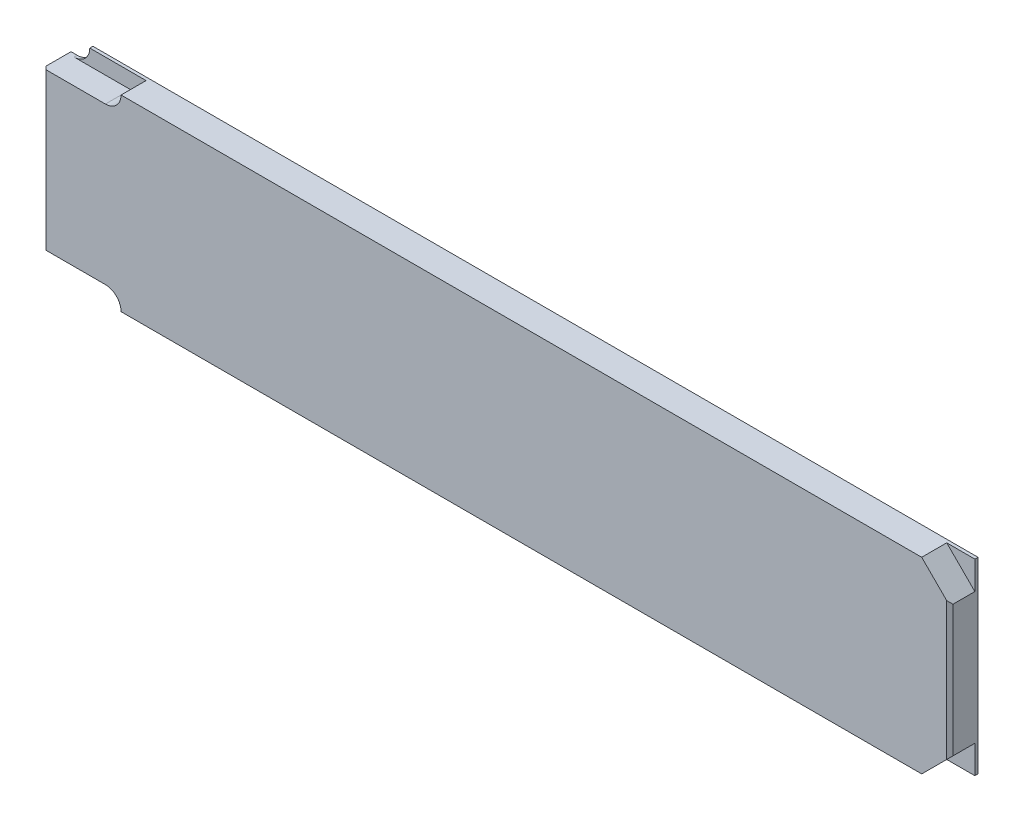
from build123d import *

# Parameters (mm, degrees)
BASE_EXTRUDE_DEPTH = 9
CUT_EXTRUDE1_DEPTH = 8
CHAMFER1_SIZE      = 1
CUT_EXTRUDE2_DEPTH = 0.13


with BuildPart() as part:
    # Sketch1 → Base-Extrude (new body)
    with BuildSketch(Plane.XY):
        with BuildLine():
            Line((7, 0), (290, 0))
            Line((290, 0), (290, 60))
            Line((290, 60), (7, 60))
            ThreePointArc((7, 60), (5.535533906, 56.464466094), (2, 55))
            Line((2, 55), (0, 55))
            Line((0, 55), (0, 5))
            Line((0, 5), (2, 5))
            ThreePointArc((2, 5), (5.535533906, 3.535533906), (7, 0))
        make_face()
    extrude(amount=BASE_EXTRUDE_DEPTH)

    # Sketch2 → Cut-Extrude1 (cut)
    with BuildSketch(Plane.XY.offset(9)):
        with BuildLine():
            Line((2, 5), (20, 5))
            ThreePointArc((20, 5), (23.535533906, 3.535533906), (25, 0))
            Line((25, 0), (7, 0))
            ThreePointArc((7, 0), (5.535533906, 3.535533906), (2, 5))
        make_face()
        Polygon((290, 60), (290, 51), (281, 60), align=None)
        Polygon((290, 9), (281, 0), (290, 0), align=None)
        with BuildLine():
            Line((25, 60), (7, 60))
            ThreePointArc((7, 60), (5.535533906, 56.464466094), (2, 55))
            Line((2, 55), (20, 55))
            ThreePointArc((20, 55), (23.535533906, 56.464466094), (25, 60))
        make_face()
    extrude(amount=-CUT_EXTRUDE1_DEPTH, mode=Mode.SUBTRACT)

    # Chamfer1
    chamfer1_edges = [part.edges().sort_by_distance(p)[0] for p in [
        (0, 30, 9),
        (290, 30, 9),
    ]]
    chamfer(chamfer1_edges, length=CHAMFER1_SIZE)

    # Sketch3 → Cut-Extrude2 (cut)
    with BuildSketch(Plane(origin=(0, 0, 0), x_dir=(-1, 0, 0), z_dir=(0, 0, -1))):
        with BuildLine():
            Line((-111.030175307, 29.245794241), (-110.20501925, 28.597628179))
            Line((-110.20501925, 28.597628179), (-113.359746321, 23.77345494))
            add(Edge.make_bspline(
                [(-113.359746321, 23.77345494), (-113.149709887, 23.806933241), (-112.740010074, 23.872236454), (-112.325308872, 23.883009243), (-112.123208114, 23.888259261)],
                knots=[0, 0, 0, 0, 1.025318673, 2, 2, 2, 2], degree=3))
            add(Edge.make_bspline(
                [(-112.123208114, 23.888259261), (-112.001858647, 23.88499765), (-111.762985832, 23.878577266), (-111.412278069, 23.829168095), (-111.075276566, 23.751304142), (-110.753378119, 23.637801551), (-110.445427333, 23.492812062), (-110.149656987, 23.319042848), (-109.871626865, 23.10752111), (-109.607756591, 22.871235599), (-109.3681889, 22.609528771), (-109.156085956, 22.33184208), (-108.977923218, 22.038464833), (-108.833371856, 21.729545624), (-108.72112251, 21.405560647), (-108.639292775, 21.066924424), (-108.590921527, 20.713403443), (-108.584353046, 20.472979242), (-108.581016459, 20.35085112)],
                knots=[0, 0, 0, 0, 1.04369286, 2.054478336, 3.041073146, 4.015093852, 4.984733326, 5.965804835, 6.960378782, 7.985147595, 9.009457201, 10.008161701, 10.986880575, 11.956520048, 12.937015923, 13.931873656, 14.949455224, 16, 16, 16, 16], degree=3))
            add(Edge.make_bspline(
                [(-108.581016459, 20.35085112), (-108.585871137, 20.183765265), (-108.595423995, 19.854979844), (-108.690613006, 19.3761088), (-108.838526994, 18.919903272), (-109.049952696, 18.49364697), (-109.312564885, 18.097924111), (-109.632812183, 17.747289134), (-109.999337206, 17.434572533), (-110.41376857, 17.173071631), (-110.859775756, 16.959512065), (-111.328328525, 16.806120858), (-111.814876559, 16.711683453), (-112.145108868, 16.699844087), (-112.312156892, 16.693855144)],
                knots=[0, 0, 0, 0, 1.031375318, 2.029502543, 3.004789286, 3.987476834, 4.960371455, 5.9300674, 6.912260825, 7.929083631, 8.949397511, 9.960523116, 10.96833055, 12, 12, 12, 12], degree=3))
            add(Edge.make_bspline(
                [(-112.312156892, 16.693855144), (-112.472819204, 16.699068356), (-112.791063115, 16.709394815), (-113.259209243, 16.801384485), (-113.709037298, 16.950483765), (-114.137395693, 17.155894444), (-114.534203503, 17.41535286), (-114.889205564, 17.727701862), (-115.200631786, 18.086264765), (-115.459806168, 18.490985951), (-115.665368492, 18.925896063), (-115.819526166, 19.379388359), (-115.90957242, 19.849810483), (-115.922155299, 20.168705347), (-115.928493004, 20.329325309)],
                knots=[0, 0, 0, 0, 1.012016664, 2.004627821, 2.994792927, 3.992885782, 4.990978636, 5.973936114, 6.964471063, 7.975201453, 8.993600317, 9.990122807, 10.98767138, 12, 12, 12, 12], degree=3))
            add(Edge.make_bspline(
                [(-115.928493004, 20.329325309), (-115.924462707, 20.45228522), (-115.916233611, 20.703345863), (-115.858775275, 21.083586266), (-115.766448372, 21.47265196), (-115.663050168, 21.802712288), (-115.553800295, 22.073099369), (-115.46287973, 22.291095161), (-115.349712335, 22.515427777), (-115.229042116, 22.753789696), (-115.090007051, 23.000037912), (-114.938831818, 23.258287989), (-114.771336785, 23.524432761), (-114.653918306, 23.705042798), (-114.593892772, 23.797372507)],
                knots=[0, 0, 0, 0, 1.173818275, 2.396712641, 3.66331629, 4.989737886, 5.693666774, 6.447286557, 7.243889047, 8.091586357, 8.998013824, 9.943181721, 10.948533338, 12, 12, 12, 12], degree=3))
            Line((-114.593892772, 23.797372507), (-111.030175307, 29.245794241))
        make_face()
        with BuildLine():
            add(Edge.make_bspline(
                [(-112.348033242, 22.663679837), (-112.438986915, 22.661025674), (-112.61664586, 22.655841324), (-112.877296643, 22.625735491), (-113.123980891, 22.569042401), (-113.359966812, 22.496837092), (-113.580842489, 22.397556998), (-113.788213185, 22.276960402), (-113.982880817, 22.134976895), (-114.162806392, 21.973617954), (-114.325934968, 21.796951966), (-114.466417329, 21.60772721), (-114.587595901, 21.410503978), (-114.68612127, 21.203634398), (-114.762842304, 20.987197553), (-114.81833865, 20.762188892), (-114.849223969, 20.527099563), (-114.854362219, 20.367679649), (-114.856986008, 20.286273689)],
                knots=[0, 0, 0, 0, 1.129588631, 2.206414736, 3.251139165, 4.268635594, 5.265702196, 6.250456724, 7.242448911, 8.251968645, 9.246821453, 10.222880186, 11.173611482, 12.116736599, 13.062300278, 14.020270554, 14.989073742, 16, 16, 16, 16], degree=3))
            add(Edge.make_bspline(
                [(-114.856986008, 20.286273689), (-114.854849283, 20.205595841), (-114.850659484, 20.047398592), (-114.812615259, 19.814271208), (-114.754502998, 19.589925509), (-114.668058587, 19.375518065), (-114.564944745, 19.167780726), (-114.428814579, 18.974238036), (-114.277976602, 18.78313518), (-114.097674478, 18.609152412), (-113.904172459, 18.447262282), (-113.697441856, 18.305759516), (-113.481982492, 18.184704525), (-113.254885509, 18.089831738), (-113.01937291, 18.0119706), (-112.773482469, 17.95717962), (-112.517043172, 17.926202964), (-112.343331719, 17.92105802), (-112.254754731, 17.918434568)],
                knots=[0, 0, 0, 0, 0.989467248, 1.94019797, 2.891935182, 3.827694429, 4.772920941, 5.730924762, 6.725747692, 7.756678648, 8.79901574, 9.819492441, 10.826891316, 11.826466727, 12.835195252, 13.867842842, 14.912794438, 16, 16, 16, 16], degree=3))
            add(Edge.make_bspline(
                [(-112.254754731, 17.918434568), (-112.166177889, 17.921058226), (-111.99246672, 17.926203573), (-111.736025361, 17.957177305), (-111.490142546, 18.011979094), (-111.254602231, 18.089800945), (-111.027607557, 18.184818755), (-110.812336629, 18.305006403), (-110.607561089, 18.448132499), (-110.413932044, 18.608875754), (-110.234380395, 18.784125422), (-110.079924728, 18.972532143), (-109.947963516, 19.169344966), (-109.840731181, 19.374699737), (-109.755238887, 19.590055151), (-109.696831939, 19.814236477), (-109.65886628, 20.047407684), (-109.654665685, 20.205598912), (-109.652523455, 20.286273689)],
                knots=[0, 0, 0, 0, 1.087397944, 2.132534446, 3.165364764, 4.174271784, 5.174024072, 6.181601208, 7.194203697, 8.236725232, 9.267838612, 10.269026844, 11.221737037, 12.171628256, 13.107553087, 14.05945871, 15.010357665, 16, 16, 16, 16], degree=3))
            add(Edge.make_bspline(
                [(-109.652523455, 20.286273689), (-109.654400685, 20.367785849), (-109.658085077, 20.52776771), (-109.69975769, 20.762083733), (-109.757553691, 20.988340792), (-109.84482581, 21.205116892), (-109.958206579, 21.411556593), (-110.096308775, 21.608702723), (-110.256070052, 21.798066747), (-110.440614525, 21.973964419), (-110.641508452, 22.134798585), (-110.855110776, 22.276776559), (-111.078579987, 22.39659939), (-111.311689505, 22.49657554), (-111.557110304, 22.568723341), (-111.81088018, 22.625533022), (-112.076244833, 22.655764275), (-112.256283175, 22.661007709), (-112.348033242, 22.663679837)],
                knots=[0, 0, 0, 0, 0.978206639, 1.919901502, 2.851605144, 3.780102724, 4.718870031, 5.675451981, 6.667674623, 7.690630536, 8.733308323, 9.756129687, 10.767539656, 11.776269907, 12.797430371, 13.836405707, 14.897401972, 16, 16, 16, 16], degree=3))
        make_face(mode=Mode.SUBTRACT)
        with BuildLine():
            Line((-105.825712755, 26.184345681), (-106.897219751, 26.184345681))
            add(Edge.make_bspline(
                [(-106.897219751, 26.184345681), (-106.868190879, 26.304535254), (-106.811441809, 26.539496039), (-106.693076991, 26.875195522), (-106.564131319, 27.192870435), (-106.409294177, 27.486572416), (-106.240403558, 27.762204007), (-106.046903728, 28.013513583), (-105.837722017, 28.246892675), (-105.606348841, 28.454005466), (-105.363705618, 28.641552555), (-105.106373358, 28.801458769), (-104.839529379, 28.939017697), (-104.561324861, 29.052342817), (-104.270931534, 29.137713097), (-103.970974713, 29.199651923), (-103.660668343, 29.239875286), (-103.450027033, 29.243800917), (-103.343069313, 29.245794241)],
                knots=[0, 0, 0, 0, 1.162005537, 2.271625781, 3.343758855, 4.383309926, 5.390229558, 6.379919256, 7.361854164, 8.333198761, 9.295911338, 10.242430842, 11.177959212, 12.116337295, 13.062827104, 14.020064771, 14.994644689, 16, 16, 16, 16], degree=3))
            add(Edge.make_bspline(
                [(-103.343069313, 29.245794241), (-103.187230478, 29.241089234), (-102.878952104, 29.231781849), (-102.426053752, 29.146790525), (-101.989312229, 29.012298451), (-101.573507977, 28.826470679), (-101.187282723, 28.59727269), (-100.843638508, 28.324486712), (-100.547233264, 28.013375945), (-100.298566604, 27.669744088), (-100.103865039, 27.302495792), (-99.960294598, 26.92452007), (-99.87289063, 26.536713533), (-99.86156312, 26.274869247), (-99.855888062, 26.143685817)],
                knots=[0, 0, 0, 0, 1.083050992, 2.142477498, 3.193116406, 4.255571735, 5.30263384, 6.308962982, 7.297363603, 8.282367274, 9.249857812, 10.179914175, 11.08814088, 12, 12, 12, 12], degree=3))
            add(Edge.make_bspline(
                [(-99.855888062, 26.143685817), (-99.859857453, 26.017443488), (-99.867624936, 25.770406839), (-99.933578555, 25.409756094), (-100.044570432, 25.069845873), (-100.198318193, 24.749245266), (-100.39734038, 24.449987029), (-100.638428158, 24.171397857), (-100.923283159, 23.912242111), (-101.139148397, 23.763782897), (-101.250282211, 23.687351699)],
                knots=[0, 0, 0, 0, 1.024540389, 2.004866551, 2.965041327, 3.920577974, 4.882998113, 5.874504559, 6.905732034, 8, 8, 8, 8], degree=3))
            add(Edge.make_bspline(
                [(-101.250282211, 23.687351699), (-101.123272469, 23.626022252), (-100.871629437, 23.504510879), (-100.52861856, 23.26620995), (-100.217239752, 22.991064662), (-100.04359045, 22.776346603), (-99.956341843, 22.66846335)],
                knots=[0, 0, 0, 0, 1.015518401, 2.012035669, 3.001164323, 4, 4, 4, 4], degree=3))
            add(Edge.make_bspline(
                [(-99.956341843, 22.66846335), (-99.898890494, 22.589805787), (-99.7849286, 22.433778734), (-99.644260653, 22.182921836), (-99.516645879, 21.929284489), (-99.417204908, 21.666068416), (-99.340198035, 21.3963244), (-99.28515273, 21.119589266), (-99.250957094, 20.835637037), (-99.246059955, 20.643536674), (-99.24359835, 20.546975168)],
                knots=[0, 0, 0, 0, 1.025084078, 2.033381695, 3.024893161, 4.013698104, 4.991890475, 5.976764909, 6.982997093, 8, 8, 8, 8], degree=3))
            add(Edge.make_bspline(
                [(-99.24359835, 20.546975168), (-99.249720025, 20.379786914), (-99.261934566, 20.046197198), (-99.371110973, 19.553346478), (-99.54035803, 19.071579911), (-99.780709777, 18.610795277), (-100.073632048, 18.179670294), (-100.422124229, 17.79392987), (-100.822226684, 17.462353511), (-101.268447708, 17.185318754), (-101.751891373, 16.963862403), (-102.268965494, 16.810156669), (-102.812219725, 16.710047827), (-103.18476168, 16.699312824), (-103.37416215, 16.693855144)],
                knots=[0, 0, 0, 0, 0.955779014, 1.907060117, 2.875433937, 3.871313158, 4.872415639, 5.851225146, 6.836215519, 7.83643374, 8.849228613, 9.86973379, 10.916971861, 12, 12, 12, 12], degree=3))
            add(Edge.make_bspline(
                [(-103.37416215, 16.693855144), (-103.501811671, 16.696816905), (-103.752983364, 16.702644662), (-104.122237483, 16.742484206), (-104.47470173, 16.815247858), (-104.810852659, 16.913164259), (-105.130988896, 17.037308442), (-105.434133541, 17.191905403), (-105.722151635, 17.373768444), (-105.992325266, 17.585044251), (-106.244622228, 17.821385652), (-106.472337691, 18.086988304), (-106.679268166, 18.376942362), (-106.859872892, 18.694615687), (-107.022378182, 19.035902914), (-107.156037292, 19.405174091), (-107.273678891, 19.799128014), (-107.328374303, 20.073664015), (-107.356437035, 20.214520988)],
                knots=[0, 0, 0, 0, 1.048658725, 2.063410685, 3.046034179, 4.001477787, 4.936774919, 5.862367409, 6.792675028, 7.730719943, 8.675894397, 9.627829632, 10.600096036, 11.597688215, 12.626045268, 13.701542398, 14.82072376, 16, 16, 16, 16], degree=3))
            Line((-107.356437035, 20.214520988), (-106.284930039, 20.214520988))
            add(Edge.make_bspline(
                [(-106.284930039, 20.214520988), (-106.257014144, 20.122589054), (-106.202715305, 19.943773457), (-106.110287757, 19.6864218), (-106.004985943, 19.450500969), (-105.892021309, 19.234280325), (-105.773380609, 19.035630477), (-105.64062902, 18.859804236), (-105.503598874, 18.699078809), (-105.400306056, 18.60852642), (-105.349753174, 18.564208874)],
                knots=[0, 0, 0, 0, 1.198163088, 2.33053128, 3.407730985, 4.417276592, 5.372219308, 6.28897303, 7.162600585, 8, 8, 8, 8], degree=3))
            add(Edge.make_bspline(
                [(-105.349753174, 18.564208874), (-105.282902816, 18.512669385), (-105.149408452, 18.409749499), (-104.931874074, 18.278407801), (-104.703093724, 18.164602388), (-104.458110287, 18.077669133), (-104.20221027, 18.004060646), (-103.931257444, 17.955890918), (-103.647642272, 17.922841384), (-103.453988788, 17.919924932), (-103.355028096, 17.918434568)],
                knots=[0, 0, 0, 0, 0.946170439, 1.889420265, 2.845303464, 3.807233317, 4.801018734, 5.828864929, 6.890507805, 8, 8, 8, 8], degree=3))
            add(Edge.make_bspline(
                [(-103.355028096, 17.918434568), (-103.243295143, 17.920535623), (-103.024810997, 17.924644055), (-102.706005782, 17.962426928), (-102.402713281, 18.017453066), (-102.118300852, 18.102439431), (-101.849042971, 18.207443024), (-101.598714066, 18.339285427), (-101.364027956, 18.493971163), (-101.147990557, 18.669788159), (-100.95373073, 18.862260407), (-100.782688385, 19.063573372), (-100.637281666, 19.272878256), (-100.51998799, 19.491333316), (-100.427368547, 19.718033925), (-100.36431628, 19.953616271), (-100.320475541, 20.196152394), (-100.316905203, 20.361018378), (-100.315105346, 20.44412963)],
                knots=[0, 0, 0, 0, 1.217147791, 2.380027433, 3.494444702, 4.572153297, 5.609568379, 6.639424714, 7.649109417, 8.668170816, 9.669597737, 10.625200337, 11.543417969, 12.441394052, 13.322311151, 14.205496177, 15.095365482, 16, 16, 16, 16], degree=3))
            add(Edge.make_bspline(
                [(-100.315105346, 20.44412963), (-100.320325707, 20.555377617), (-100.330740453, 20.777320035), (-100.410253672, 21.103844114), (-100.541040128, 21.41844846), (-100.72413469, 21.715765481), (-100.947016317, 21.991318608), (-101.207522092, 22.237178102), (-101.507815287, 22.440050113), (-101.784200667, 22.580217013), (-102.029015183, 22.675860684), (-102.238523228, 22.73956712), (-102.473074582, 22.793512693), (-102.729832815, 22.843701083), (-103.010732567, 22.886415513), (-103.315468027, 22.922035976), (-103.644100946, 22.950537764), (-103.871606414, 22.963265755), (-103.988843618, 22.969824693)],
                knots=[0, 0, 0, 0, 1.07054697, 2.135767047, 3.216561865, 4.33974944, 5.486079747, 6.621378074, 7.775625952, 8.963672916, 9.598146892, 10.304877434, 11.070270905, 11.915000392, 12.823868403, 13.805723172, 14.86925407, 16, 16, 16, 16], degree=3))
            Line((-103.988843618, 22.969824693), (-103.988843618, 24.194404117))
            add(Edge.make_bspline(
                [(-103.988843618, 24.194404117), (-103.841129122, 24.196910774), (-103.551792711, 24.201820699), (-103.129148551, 24.261205139), (-102.724997177, 24.343352069), (-102.348295296, 24.469179573), (-102.004949483, 24.615321894), (-101.707073645, 24.785384152), (-101.458841009, 24.974422059), (-101.261457893, 25.185353396), (-101.112965399, 25.4115758), (-101.004393741, 25.647355417), (-100.940259654, 25.894758806), (-100.931698356, 26.063601372), (-100.927395058, 26.148469331)],
                knots=[0, 0, 0, 0, 1.321986639, 2.589447074, 3.816329219, 5.01088745, 6.139805852, 7.153945165, 8.075214402, 8.924034688, 9.728124013, 10.488707548, 11.240355623, 12, 12, 12, 12], degree=3))
            add(Edge.make_bspline(
                [(-100.927395058, 26.148469331), (-100.92880875, 26.210820722), (-100.931621223, 26.334865857), (-100.967089752, 26.516092912), (-101.020388487, 26.691779552), (-101.093662897, 26.86117865), (-101.191739266, 27.023115343), (-101.309109385, 27.178970235), (-101.448865029, 27.327853498), (-101.609011365, 27.466627427), (-101.780982587, 27.598882027), (-101.969457714, 27.711161251), (-102.168753914, 27.8071733), (-102.379091834, 27.886348534), (-102.601154065, 27.9459079), (-102.833897258, 27.988671771), (-103.077765223, 28.015408586), (-103.244141617, 28.019257983), (-103.328718773, 28.021214817)],
                knots=[0, 0, 0, 0, 0.884392785, 1.759457502, 2.611959086, 3.489218968, 4.37281399, 5.2945488, 6.255912374, 7.266815255, 8.301784654, 9.332968512, 10.37626691, 11.440494194, 12.520033166, 13.637162961, 14.798855837, 16, 16, 16, 16], degree=3))
            add(Edge.make_bspline(
                [(-103.328718773, 28.021214817), (-103.464665899, 28.016468425), (-103.730202257, 28.007197616), (-104.113004189, 27.92599772), (-104.468871695, 27.796442005), (-104.740886473, 27.641796189), (-104.94175427, 27.489137763), (-105.085292524, 27.355814909), (-105.226250355, 27.207651284), (-105.355354387, 27.035521196), (-105.48591949, 26.851081619), (-105.604785733, 26.644956598), (-105.720292262, 26.422522997), (-105.789892059, 26.26527565), (-105.825712755, 26.184345681)],
                knots=[0, 0, 0, 0, 1.472543308, 2.876219568, 4.221790263, 5.565193594, 6.249813518, 6.953379497, 7.687249741, 8.463570142, 9.283606569, 10.136032583, 11.040678096, 12, 12, 12, 12], degree=3))
        make_face()
        Polygon((-97.406729214, 28.939649385), (-90.059252669, 28.939649385), (-96.335222218, 16.693855144), (-97.260832056, 17.203299318), (-91.872204238, 27.715069961), (-97.406729214, 27.715069961), align=None)
        with BuildLine():
            Line((-83.477138264, 29.245794241), (-82.651982207, 28.597628179))
            Line((-82.651982207, 28.597628179), (-85.806709278, 23.77345494))
            add(Edge.make_bspline(
                [(-85.806709278, 23.77345494), (-85.596672844, 23.806933241), (-85.186973031, 23.872236454), (-84.772271829, 23.883009243), (-84.57017107, 23.888259261)],
                knots=[0, 0, 0, 0, 1.025318673, 2, 2, 2, 2], degree=3))
            add(Edge.make_bspline(
                [(-84.57017107, 23.888259261), (-84.448821604, 23.88499765), (-84.209948789, 23.878577266), (-83.859241026, 23.829168095), (-83.522239523, 23.751304142), (-83.200341076, 23.637801551), (-82.892390289, 23.492812062), (-82.596619944, 23.319042848), (-82.318589822, 23.10752111), (-82.054719548, 22.871235599), (-81.815151857, 22.609528771), (-81.603048913, 22.33184208), (-81.424886175, 22.038464833), (-81.280334813, 21.729545624), (-81.168085466, 21.405560647), (-81.086255732, 21.066924424), (-81.037884484, 20.713403443), (-81.031316003, 20.472979242), (-81.027979416, 20.35085112)],
                knots=[0, 0, 0, 0, 1.04369286, 2.054478336, 3.041073146, 4.015093852, 4.984733326, 5.965804835, 6.960378782, 7.985147595, 9.009457201, 10.008161701, 10.986880575, 11.956520048, 12.937015923, 13.931873656, 14.949455224, 16, 16, 16, 16], degree=3))
            add(Edge.make_bspline(
                [(-81.027979416, 20.35085112), (-81.032834094, 20.183765265), (-81.042386952, 19.854979844), (-81.137575963, 19.3761088), (-81.285489951, 18.919903272), (-81.496915653, 18.49364697), (-81.759527842, 18.097924111), (-82.07977514, 17.747289134), (-82.446300163, 17.434572533), (-82.860731527, 17.173071631), (-83.306738713, 16.959512065), (-83.775291482, 16.806120858), (-84.261839516, 16.711683453), (-84.592071825, 16.699844087), (-84.759119849, 16.693855144)],
                knots=[0, 0, 0, 0, 1.031375318, 2.029502543, 3.004789286, 3.987476834, 4.960371455, 5.9300674, 6.912260825, 7.929083631, 8.949397511, 9.960523116, 10.96833055, 12, 12, 12, 12], degree=3))
            add(Edge.make_bspline(
                [(-84.759119849, 16.693855144), (-84.919782161, 16.699068356), (-85.238026072, 16.709394815), (-85.7061722, 16.801384485), (-86.156000255, 16.950483765), (-86.58435865, 17.155894444), (-86.98116646, 17.41535286), (-87.33616852, 17.727701862), (-87.647594743, 18.086264765), (-87.906769125, 18.490985951), (-88.112331448, 18.925896063), (-88.266489123, 19.379388359), (-88.356535377, 19.849810483), (-88.369118256, 20.168705347), (-88.375455961, 20.329325309)],
                knots=[0, 0, 0, 0, 1.012016664, 2.004627821, 2.994792927, 3.992885782, 4.990978636, 5.973936114, 6.964471063, 7.975201453, 8.993600317, 9.990122807, 10.98767138, 12, 12, 12, 12], degree=3))
            add(Edge.make_bspline(
                [(-88.375455961, 20.329325309), (-88.371425664, 20.45228522), (-88.363196568, 20.703345863), (-88.305738232, 21.083586266), (-88.213411329, 21.47265196), (-88.110013125, 21.802712288), (-88.000763252, 22.073099369), (-87.909842687, 22.291095161), (-87.796675292, 22.515427777), (-87.676005072, 22.753789696), (-87.536970008, 23.000037912), (-87.385794775, 23.258287989), (-87.218299742, 23.524432761), (-87.100881263, 23.705042798), (-87.040855729, 23.797372507)],
                knots=[0, 0, 0, 0, 1.173818275, 2.396712641, 3.66331629, 4.989737886, 5.693666774, 6.447286557, 7.243889047, 8.091586357, 8.998013824, 9.943181721, 10.948533338, 12, 12, 12, 12], degree=3))
            Line((-87.040855729, 23.797372507), (-83.477138264, 29.245794241))
        make_face()
        with BuildLine():
            add(Edge.make_bspline(
                [(-84.794996199, 22.663679837), (-84.885949872, 22.661025674), (-85.063608817, 22.655841324), (-85.3242596, 22.625735491), (-85.570943848, 22.569042401), (-85.806929769, 22.496837092), (-86.027805446, 22.397556998), (-86.235176142, 22.276960402), (-86.429843774, 22.134976895), (-86.609769349, 21.973617954), (-86.772897925, 21.796951966), (-86.913380286, 21.60772721), (-87.034558858, 21.410503978), (-87.133084227, 21.203634398), (-87.209805261, 20.987197553), (-87.265301607, 20.762188892), (-87.296186925, 20.527099563), (-87.301325176, 20.367679649), (-87.303948965, 20.286273689)],
                knots=[0, 0, 0, 0, 1.129588631, 2.206414736, 3.251139165, 4.268635594, 5.265702196, 6.250456724, 7.242448911, 8.251968645, 9.246821453, 10.222880186, 11.173611482, 12.116736599, 13.062300278, 14.020270554, 14.989073742, 16, 16, 16, 16], degree=3))
            add(Edge.make_bspline(
                [(-87.303948965, 20.286273689), (-87.30181224, 20.205595841), (-87.297622441, 20.047398592), (-87.259578215, 19.814271208), (-87.201465955, 19.589925509), (-87.115021543, 19.375518065), (-87.011907701, 19.167780726), (-86.875777536, 18.974238036), (-86.724939559, 18.78313518), (-86.544637435, 18.609152412), (-86.351135416, 18.447262282), (-86.144404813, 18.305759516), (-85.928945449, 18.184704525), (-85.701848466, 18.089831738), (-85.466335866, 18.0119706), (-85.220445426, 17.95717962), (-84.964006129, 17.926202964), (-84.790294676, 17.92105802), (-84.701717688, 17.918434568)],
                knots=[0, 0, 0, 0, 0.989467248, 1.94019797, 2.891935182, 3.827694429, 4.772920941, 5.730924762, 6.725747692, 7.756678648, 8.79901574, 9.819492441, 10.826891316, 11.826466727, 12.835195252, 13.867842842, 14.912794438, 16, 16, 16, 16], degree=3))
            add(Edge.make_bspline(
                [(-84.701717688, 17.918434568), (-84.613140846, 17.921058226), (-84.439429677, 17.926203573), (-84.182988318, 17.957177305), (-83.937105503, 18.011979094), (-83.701565187, 18.089800945), (-83.474570514, 18.184818755), (-83.259299586, 18.305006403), (-83.054524046, 18.448132499), (-82.860895001, 18.608875754), (-82.681343352, 18.784125422), (-82.526887685, 18.972532143), (-82.394926473, 19.169344966), (-82.287694138, 19.374699737), (-82.202201843, 19.590055151), (-82.143794896, 19.814236477), (-82.105829237, 20.047407684), (-82.101628642, 20.205598912), (-82.099486412, 20.286273689)],
                knots=[0, 0, 0, 0, 1.087397944, 2.132534446, 3.165364764, 4.174271784, 5.174024072, 6.181601208, 7.194203697, 8.236725232, 9.267838612, 10.269026844, 11.221737037, 12.171628256, 13.107553087, 14.05945871, 15.010357665, 16, 16, 16, 16], degree=3))
            add(Edge.make_bspline(
                [(-82.099486412, 20.286273689), (-82.101363642, 20.367785849), (-82.105048034, 20.52776771), (-82.146720647, 20.762083733), (-82.204516648, 20.988340792), (-82.291788767, 21.205116892), (-82.405169536, 21.411556593), (-82.543271732, 21.608702723), (-82.703033009, 21.798066747), (-82.887577481, 21.973964419), (-83.088471409, 22.134798585), (-83.302073733, 22.276776559), (-83.525542944, 22.39659939), (-83.758652462, 22.49657554), (-84.004073261, 22.568723341), (-84.257843137, 22.625533022), (-84.523207789, 22.655764275), (-84.703246132, 22.661007709), (-84.794996199, 22.663679837)],
                knots=[0, 0, 0, 0, 0.978206639, 1.919901502, 2.851605144, 3.780102724, 4.718870031, 5.675451981, 6.667674623, 7.690630536, 8.733308323, 9.756129687, 10.767539656, 11.776269907, 12.797430371, 13.836405707, 14.897401972, 16, 16, 16, 16], degree=3))
        make_face(mode=Mode.SUBTRACT)
        Polygon((-77.265746146, 28.939649385), (-75.058154723, 28.939649385), (-75.058154723, 17), (-76.129661719, 17), (-76.129661719, 27.715069961), (-77.966530855, 27.715069961), align=None)
    extrude(amount=-CUT_EXTRUDE2_DEPTH, mode=Mode.SUBTRACT)


solid = part.part
